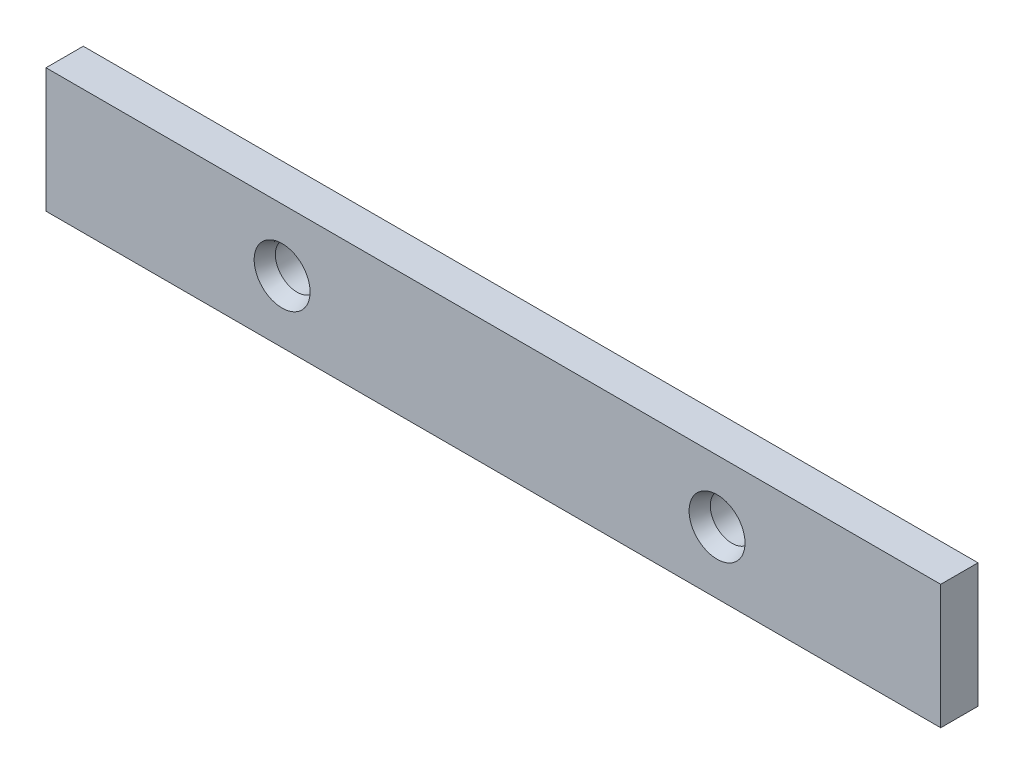
from build123d import *

# Parameters (mm, degrees)
SKETCH1_W           = 144
SKETCH1_H           = 20
BOSS_EXTRUDE1_DEPTH = 3
LPATTERN1_COUNT     = 2
LPATTERN1_PITCH     = 70


with BuildPart() as part:
    # Sketch1 → Boss-Extrude1 (new body, symmetric)
    with BuildSketch(Plane.XY):
        Rectangle(SKETCH1_W, SKETCH1_H)
    extrude(amount=BOSS_EXTRUDE1_DEPTH, both=True)

    # Sketch6 → Hole1 (revolve, cut)
    with BuildSketch(Plane(origin=(-34, 0, 3), x_dir=(0, -1, 0), z_dir=(1, 0, 0))):
        Polygon((0, 0), (0, 6), (3.5, 6), (3.5, 2.414213562), (4.5, 0), align=None)
    hole1 = revolve(axis=Axis((-34, 0, 9.445314094), (0, 0, -1)), mode=Mode.SUBTRACT)

    # LPattern1: Hole1 ×2
    with Locations(*[(i * LPATTERN1_PITCH, 0, 0) for i in range(1, LPATTERN1_COUNT)]):
        add(hole1, mode=Mode.SUBTRACT)


solid = part.part
